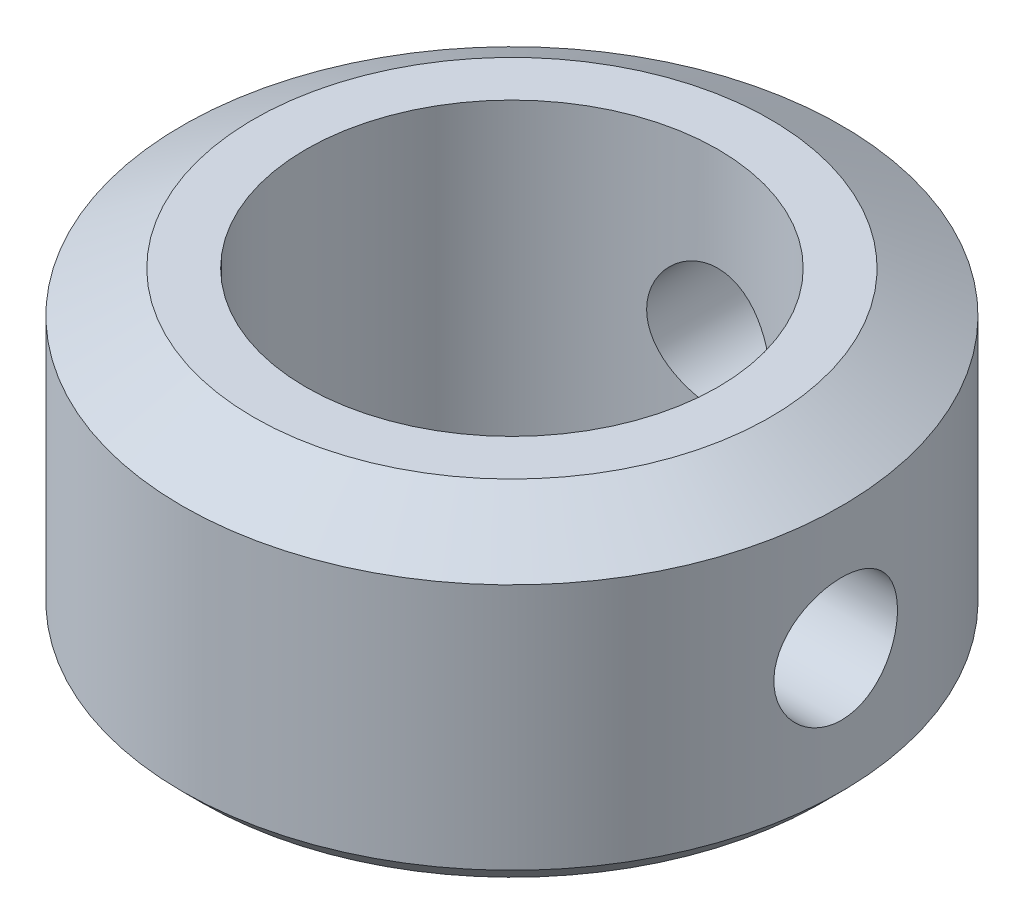
from build123d import *

# Parameters (mm, degrees)
SKETCH1_R           = 8
SKETCH1_R_2         = 5
BOSS_EXTRUDE1_DEPTH = 7.5
CHAMFER1_SIZE       = 1
CHAMFER1_SIZE2      = 1.732050808
CHAMFER2_SIZE       = 0.5
CHAMFER3_SIZE       = 0.2
CUT_EXTRUDE1_START  = -3.230304
SKETCH2_R           = 1.5
CUT_EXTRUDE1_DEPTH  = 3.230304
CIRPATTERN1_COUNT   = 2
CIRPATTERN1_ANGLE   = 90


with BuildPart() as part:
    # Sketch1 → Boss-Extrude1 (new body)
    with BuildSketch(Plane(origin=(0, 0, 0), x_dir=(1, 0, 0), z_dir=(0, 1, 0))):
        Circle(SKETCH1_R)
        Circle(SKETCH1_R_2, mode=Mode.SUBTRACT)
    extrude(amount=BOSS_EXTRUDE1_DEPTH)

    # Chamfer1
    chamfer1_edges = [part.edges().sort_by_distance(p)[0] for p in [
        (-8, 7.5, 0),
    ]]
    chamfer1_side = [part.faces().sort_by_distance(p)[0] for p in [
        (-8, 3.75, 0),
    ]]
    chamfer(chamfer1_edges, length=CHAMFER1_SIZE, length2=CHAMFER1_SIZE2, reference=chamfer1_side[0])

    # Chamfer2
    chamfer2_edges = [part.edges().sort_by_distance(p)[0] for p in [
        (-8, 0, 0),
    ]]
    chamfer(chamfer2_edges, length=CHAMFER2_SIZE)

    # Chamfer3
    chamfer3_edges = [part.edges().sort_by_distance(p)[0] for p in [
        (-5, 0, 0),
    ]]
    chamfer(chamfer3_edges, length=CHAMFER3_SIZE)

    # Sketch2 → Cut-Extrude1 (cut)
    with BuildSketch(Plane(origin=(8, 0, 0), x_dir=(0, 0, -1), z_dir=(1, 0, 0)).offset(CUT_EXTRUDE1_START)):
        with Locations((0, 3.5)):
            Circle(SKETCH2_R)
    cut_extrude1 = extrude(amount=CUT_EXTRUDE1_DEPTH, mode=Mode.SUBTRACT)

    # CirPattern1: Cut-Extrude1 ×2 about axis
    cirpattern1_axis = Axis((0, 7.5, 0), (0, 1, 0))
    for i in range(1, CIRPATTERN1_COUNT):
        add(cut_extrude1.rotate(cirpattern1_axis, i * CIRPATTERN1_ANGLE / (CIRPATTERN1_COUNT - 1)), mode=Mode.SUBTRACT)


solid = part.part
